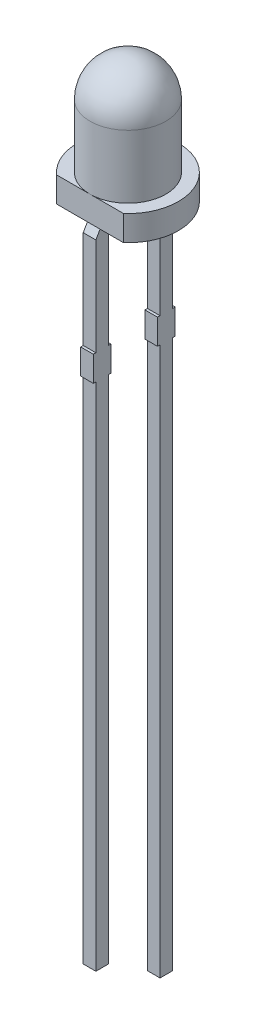
from build123d import *

# Parameters (mm, degrees)
EXTRUDE1_DEPTH     = 1
SKETCH3_W          = 0.7
SKETCH3_H          = 1
EXTRUDE2_DEPTH     = 0.25
SKETCH3_4_W        = 0.7
SKETCH3_4_H        = 1
EXTRUDE3_DEPTH     = 0.25
FILLET1_R          = 0.25
FILLET2_R          = 0.25
SKETCH4_W          = 0.026582279
SKETCH4_H          = 0.025316456
SKETCH4_H_2        = 0.025316455
CUT_EXTRUDE1_DEPTH = 0.01


with BuildPart() as part:
    # Sketch1 → Revolve1 (revolve)
    with BuildSketch(Plane.XY):
        with BuildLine():
            ThreePointArc((0, 4), (1.060660172, 3.560660172), (1.5, 2.5))
            Line((1.5, 2.5), (1.5, 0))
            Line((1.5, 0), (0, 0))
            Line((0, 0), (0, 4))
        make_face()
    revolve(axis=Axis((0, 0, 0), (0, 1, 0)))

    # Sketch2 → Extrude1 (add)
    with BuildSketch(Plane.XZ.offset(1)):
        with BuildLine():
            Line((-1.322875656, 1.5), (1.322875656, 1.5))
            ThreePointArc((1.322875656, 1.5), (0, -2), (-1.322875656, 1.5))
        make_face()
    extrude(amount=-EXTRUDE1_DEPTH)

    # Sketch4 → Cut-Extrude1 (cut)
    with BuildSketch(Plane.XZ.offset(1)):
        Polygon((-0.985888894, 0.474333212), (-1.060572439, 0.49779049), (-1.060572439, 0.52253337), (-1.010236204, 0.538949509), (-1.060572439, 0.554475617), (-1.060572439, 0.580207421), (-0.985888894, 0.603447136), (-0.985888894, 0.57826913), (-1.03737228, 0.565274668), (-0.985888894, 0.548858528), (-0.985888894, 0.52735932), (-1.03737228, 0.511042073), (-0.985888894, 0.498225617), align=None)
        Polygon((-0.985888894, 0.340155997), (-1.060572439, 0.363613275), (-1.060572439, 0.388356155), (-1.010236204, 0.404772294), (-1.060572439, 0.420298402), (-1.060572439, 0.446030206), (-0.985888894, 0.469269921), (-0.985888894, 0.444091914), (-1.03737228, 0.431097452), (-0.985888894, 0.414681313), (-0.985888894, 0.393182104), (-1.03737228, 0.376864858), (-0.985888894, 0.364048402), align=None)
        Polygon((-0.985888894, 0.205978782), (-1.060572439, 0.22943606), (-1.060572439, 0.25417894), (-1.010236204, 0.270595079), (-1.060572439, 0.286121187), (-1.060572439, 0.31185299), (-0.985888894, 0.335092706), (-0.985888894, 0.309914699), (-1.03737228, 0.296920237), (-0.985888894, 0.280504098), (-0.985888894, 0.259004889), (-1.03737228, 0.242687642), (-0.985888894, 0.229871187), align=None)
        with Locations((-1.0472813, 0.17813068)):
            Rectangle(SKETCH4_W, SKETCH4_H)
        with BuildLine():
            add(Edge.make_bspline(
                [(-1.029401552, 0.061674984), (-1.030623686, 0.061711482), (-1.033023549, 0.061783153), (-1.036531237, 0.062392739), (-1.03985554, 0.063386706), (-1.043019686, 0.064759045), (-1.045989175, 0.066552502), (-1.048792066, 0.068735773), (-1.05139661, 0.071324656), (-1.053832985, 0.07427146), (-1.056015096, 0.077568402), (-1.05792113, 0.081166117), (-1.059515801, 0.085046144), (-1.060854866, 0.089194355), (-1.0618433, 0.093640901), (-1.062567287, 0.0983584), (-1.063040605, 0.103351827), (-1.063082573, 0.106775404), (-1.063104084, 0.108530206)],
                knots=[0, 0, 0, 0, 0.907312236, 1.78165839, 2.635367075, 3.479697475, 4.336364812, 5.205276731, 6.11257575, 7.058770404, 8.040786331, 9.044147278, 10.078219212, 11.153049307, 12.278104542, 13.457648573, 14.696882856, 16, 16, 16, 16], degree=3))
            add(Edge.make_bspline(
                [(-1.063104084, 0.108530206), (-1.063080012, 0.110548461), (-1.063033388, 0.114457643), (-1.062604789, 0.120121168), (-1.061958649, 0.125389206), (-1.060992107, 0.13028492), (-1.059791342, 0.13488952), (-1.058500051, 0.139322787), (-1.057035635, 0.143604099), (-1.055935477, 0.146377189), (-1.055390477, 0.147750933)],
                knots=[0, 0, 0, 0, 1.203215828, 2.33052265, 3.384689099, 4.366106119, 5.303329643, 6.221311756, 7.118865988, 8, 8, 8, 8], degree=3))
            Line((-1.055390477, 0.147750933), (-1.031458515, 0.147750933))
            Line((-1.031458515, 0.147750933), (-1.031458515, 0.144902832))
            add(Edge.make_bspline(
                [(-1.031458515, 0.144902832), (-1.03253997, 0.143537518), (-1.03469653, 0.140814905), (-1.037459136, 0.136381672), (-1.039861299, 0.131734027), (-1.0418353, 0.126888556), (-1.043421624, 0.121991711), (-1.044515152, 0.117116334), (-1.045262501, 0.112350746), (-1.045343007, 0.109192177), (-1.045382565, 0.107640174)],
                knots=[0, 0, 0, 0, 1.030622468, 2.055194264, 3.087043286, 4.125157485, 5.149848264, 6.130935704, 7.081611712, 8, 8, 8, 8], degree=3))
            add(Edge.make_bspline(
                [(-1.045382565, 0.107640174), (-1.045381671, 0.107211395), (-1.045379756, 0.106293414), (-1.045250913, 0.104825377), (-1.045157749, 0.103166777), (-1.044948532, 0.101387911), (-1.044729948, 0.099597094), (-1.044349628, 0.097942434), (-1.04398779, 0.096438795), (-1.043619612, 0.095532313), (-1.043444274, 0.095100617)],
                knots=[0, 0, 0, 0, 0.806378557, 1.726393851, 2.771014456, 3.931269413, 5.096090628, 6.161710732, 7.124547685, 8, 8, 8, 8], degree=3))
            add(Edge.make_bspline(
                [(-1.043444274, 0.095100617), (-1.04321645, 0.09462083), (-1.042768728, 0.093677947), (-1.041951121, 0.092383028), (-1.04107982, 0.091200355), (-1.040114401, 0.090138895), (-1.038936492, 0.089288627), (-1.037535636, 0.088660426), (-1.035885336, 0.088317332), (-1.034710325, 0.088278039), (-1.034089052, 0.088257263)],
                knots=[0, 0, 0, 0, 1.024407818, 2.013179384, 2.949802342, 3.859052226, 4.77034807, 5.732977883, 6.801339628, 8, 8, 8, 8], degree=3))
            add(Edge.make_bspline(
                [(-1.034089052, 0.088257263), (-1.033543156, 0.088288704), (-1.032469764, 0.088350528), (-1.030941767, 0.088932319), (-1.029519891, 0.089815218), (-1.028259175, 0.09110224), (-1.027101737, 0.092696316), (-1.02613144, 0.094652053), (-1.025251366, 0.096905033), (-1.024834098, 0.098549492), (-1.02461516, 0.099412326)],
                knots=[0, 0, 0, 0, 0.825212765, 1.622611382, 2.449701629, 3.348069183, 4.336544339, 5.428209675, 6.6506027, 8, 8, 8, 8], degree=3))
            add(Edge.make_bspline(
                [(-1.02461516, 0.099412326), (-1.024167419, 0.101381053), (-1.02325023, 0.105413961), (-1.022103122, 0.11156207), (-1.020837049, 0.117692298), (-1.019627508, 0.121651009), (-1.019037628, 0.12358163)],
                knots=[0, 0, 0, 0, 0.976104583, 1.999535498, 3.024395274, 4, 4, 4, 4], degree=3))
            add(Edge.make_bspline(
                [(-1.019037628, 0.12358163), (-1.018684636, 0.124620145), (-1.017997503, 0.126641714), (-1.016835878, 0.129533258), (-1.015565926, 0.132194371), (-1.014210794, 0.134634481), (-1.012736796, 0.136833803), (-1.011203407, 0.138828993), (-1.009549569, 0.140572519), (-1.00781765, 0.142120202), (-1.005965647, 0.143443517), (-1.004021511, 0.144598267), (-1.001961045, 0.145573902), (-0.999799757, 0.146382786), (-0.997520888, 0.146999859), (-0.995144015, 0.147421115), (-0.992660654, 0.147719504), (-0.990966301, 0.147740314), (-0.990101711, 0.147750933)],
                knots=[0, 0, 0, 0, 1.287286806, 2.505824366, 3.654938963, 4.74627059, 5.778586806, 6.75996495, 7.696030012, 8.595059759, 9.482019644, 10.363222407, 11.245851011, 12.154256429, 13.068444161, 14.012503255, 14.985824751, 16, 16, 16, 16], degree=3))
            add(Edge.make_bspline(
                [(-0.990101711, 0.147750933), (-0.988945566, 0.147713632), (-0.986670294, 0.147640222), (-0.983341249, 0.147038793), (-0.980192513, 0.146012204), (-0.97718905, 0.14462614), (-0.974375964, 0.142797512), (-0.971697416, 0.140612718), (-0.969225825, 0.13798867), (-0.966925491, 0.135011549), (-0.964846093, 0.131724164), (-0.963015536, 0.128185181), (-0.961478885, 0.124415892), (-0.960204991, 0.120430345), (-0.95925032, 0.116211876), (-0.958531388, 0.111774643), (-0.958118207, 0.107100854), (-0.958066956, 0.103909433), (-0.958040793, 0.102280206)],
                knots=[0, 0, 0, 0, 0.894990994, 1.761326291, 2.609044902, 3.454222546, 4.315366365, 5.200560057, 6.125081389, 7.100429509, 8.110379559, 9.133447974, 10.182136699, 11.259192205, 12.370181258, 13.528580438, 14.738335141, 16, 16, 16, 16], degree=3))
            add(Edge.make_bspline(
                [(-0.958040793, 0.102280206), (-0.958062985, 0.100611519), (-0.95810733, 0.097276974), (-0.958485307, 0.092295531), (-0.959040536, 0.087335029), (-0.959882241, 0.082471199), (-0.960858658, 0.077780644), (-0.961954454, 0.073367408), (-0.963192418, 0.069287948), (-0.964146763, 0.066714283), (-0.964607249, 0.065472452)],
                knots=[0, 0, 0, 0, 1.065403572, 2.129000689, 3.188532477, 4.251604565, 5.279552602, 6.247508681, 7.154397237, 8, 8, 8, 8], degree=3))
            Line((-0.964607249, 0.065472452), (-0.987154717, 0.065472452))
            Line((-0.987154717, 0.065472452), (-0.987154717, 0.068300775))
            add(Edge.make_bspline(
                [(-0.987154717, 0.068300775), (-0.98635437, 0.06937368), (-0.984717641, 0.071567798), (-0.982633968, 0.075227435), (-0.980676103, 0.079185671), (-0.978991944, 0.083464501), (-0.977532462, 0.087923529), (-0.976513296, 0.092506488), (-0.975871487, 0.097132651), (-0.975798712, 0.100234362), (-0.975762312, 0.101785744)],
                knots=[0, 0, 0, 0, 0.892283326, 1.824742884, 2.804416662, 3.836872171, 4.8899239, 5.931447339, 6.965372909, 8, 8, 8, 8], degree=3))
            add(Edge.make_bspline(
                [(-0.975762312, 0.101785744), (-0.975783764, 0.102881411), (-0.975826667, 0.105072628), (-0.976217351, 0.108340836), (-0.976848244, 0.111582897), (-0.977667526, 0.11362342), (-0.978076394, 0.114641756)],
                knots=[0, 0, 0, 0, 0.999146175, 1.998183711, 3.000980573, 4, 4, 4, 4], degree=3))
            add(Edge.make_bspline(
                [(-0.978076394, 0.114641756), (-0.978277861, 0.11507526), (-0.97868066, 0.115941977), (-0.979453224, 0.117148622), (-0.980382035, 0.11825329), (-0.981434027, 0.119245368), (-0.982590401, 0.120113765), (-0.983865227, 0.120729117), (-0.985228142, 0.12110499), (-0.986163373, 0.121147148), (-0.986640477, 0.121168655)],
                knots=[0, 0, 0, 0, 1.00524851, 2.009826503, 3.004679593, 4.035271301, 5.048246368, 6.034938417, 6.997532266, 8, 8, 8, 8], degree=3))
            add(Edge.make_bspline(
                [(-0.986640477, 0.121168655), (-0.987278642, 0.121134217), (-0.988498118, 0.121068409), (-0.990213913, 0.120461824), (-0.991692347, 0.119476991), (-0.992687267, 0.118316386), (-0.993384706, 0.117199256), (-0.993895216, 0.116163597), (-0.994378575, 0.11495437), (-0.994876043, 0.113583122), (-0.995367231, 0.112046795), (-0.995842777, 0.110338238), (-0.996292073, 0.108455521), (-0.996578264, 0.107139646), (-0.996727502, 0.106453465)],
                knots=[0, 0, 0, 0, 1.173816843, 2.243057204, 3.312297565, 4.415174738, 5.03266065, 5.73970059, 6.541434878, 7.433956553, 8.430083051, 9.515931566, 10.70464786, 12, 12, 12, 12], degree=3))
            add(Edge.make_bspline(
                [(-0.996727502, 0.106453465), (-0.997103563, 0.104620676), (-0.997842441, 0.10101965), (-0.998945929, 0.095618466), (-1.000220899, 0.090115693), (-1.001369702, 0.086450366), (-1.001968799, 0.084538908)],
                knots=[0, 0, 0, 0, 0.995744513, 1.956417928, 2.934277412, 4, 4, 4, 4], degree=3))
            add(Edge.make_bspline(
                [(-1.001968799, 0.084538908), (-1.002288043, 0.083592354), (-1.002912536, 0.081740741), (-1.003998819, 0.07910011), (-1.005172801, 0.076653052), (-1.006414333, 0.074386019), (-1.007758299, 0.072312049), (-1.009180946, 0.070417367), (-1.010707855, 0.068733548), (-1.012321082, 0.067235983), (-1.014031183, 0.065916823), (-1.015870255, 0.064784525), (-1.017819057, 0.063812297), (-1.019905257, 0.063042692), (-1.022099845, 0.062424671), (-1.024431212, 0.062001574), (-1.026875589, 0.061707591), (-1.028550166, 0.061685974), (-1.029401552, 0.061674984)],
                knots=[0, 0, 0, 0, 1.237467875, 2.420686895, 3.535046182, 4.599015201, 5.620884487, 6.594603852, 7.531477383, 8.433220087, 9.318759595, 10.202828513, 11.105163009, 12.01247538, 12.953896178, 13.926381251, 14.945733412, 16, 16, 16, 16], degree=3))
        make_face()
        with BuildLine():
            Line((-1.060572439, -0.030730079), (-1.060572439, -0.006679446))
            Line((-1.060572439, -0.006679446), (-1.05274016, -0.006679446))
            add(Edge.make_bspline(
                [(-1.05274016, -0.006679446), (-1.053548718, -0.005586137), (-1.055107607, -0.003478254), (-1.057187824, -0.000305229), (-1.058963091, 0.002720862), (-1.060522311, 0.005634352), (-1.061697697, 0.008656555), (-1.062525763, 0.01188807), (-1.063025536, 0.015390894), (-1.063077319, 0.017817788), (-1.063104084, 0.019072136)],
                knots=[0, 0, 0, 0, 1.150872466, 2.218865267, 3.209461834, 4.120482262, 5.012764827, 5.946708227, 6.938749913, 8, 8, 8, 8], degree=3))
            add(Edge.make_bspline(
                [(-1.063104084, 0.019072136), (-1.063081365, 0.020088488), (-1.063037125, 0.022067618), (-1.062692247, 0.024944858), (-1.062154595, 0.027652486), (-1.061347004, 0.030167526), (-1.060381201, 0.032531515), (-1.059101243, 0.034669065), (-1.057671069, 0.036672667), (-1.055964024, 0.03845434), (-1.05406629, 0.040069961), (-1.05193383, 0.041452511), (-1.049600905, 0.042630222), (-1.047049051, 0.04357132), (-1.044290747, 0.044326409), (-1.0413115, 0.044850341), (-1.038124372, 0.045170934), (-1.035929242, 0.045202873), (-1.034801078, 0.045219288)],
                knots=[0, 0, 0, 0, 1.109008058, 2.159558935, 3.158726032, 4.116861086, 5.039058877, 5.938775559, 6.82970133, 7.720510853, 8.624361809, 9.544451588, 10.487360536, 11.471068125, 12.508000841, 13.604731202, 14.768976642, 16, 16, 16, 16], degree=3))
            Line((-1.034801078, 0.045219288), (-0.985888894, 0.045219288))
            Line((-0.985888894, 0.045219288), (-0.985888894, 0.021168655))
            Line((-0.985888894, 0.021168655), (-1.023468008, 0.021168655))
            add(Edge.make_bspline(
                [(-1.023468008, 0.021168655), (-1.024384479, 0.021167019), (-1.026138695, 0.021163889), (-1.028644501, 0.02108155), (-1.030912674, 0.020960649), (-1.032954703, 0.020821945), (-1.034801453, 0.020568928), (-1.036467614, 0.02019122), (-1.037987216, 0.019720393), (-1.038893918, 0.019256075), (-1.03933035, 0.019032579)],
                knots=[0, 0, 0, 0, 1.361401701, 2.605856924, 3.723918663, 4.735739235, 5.645738665, 6.489217889, 7.27279937, 8, 8, 8, 8], degree=3))
            add(Edge.make_bspline(
                [(-1.03933035, 0.019032579), (-1.039729065, 0.018802572), (-1.040512904, 0.018350399), (-1.041519082, 0.017430109), (-1.04236335, 0.016351366), (-1.043019379, 0.015073763), (-1.043518327, 0.013587214), (-1.043858564, 0.011859284), (-1.044074065, 0.009873922), (-1.044101974, 0.008464904), (-1.044116742, 0.007719288)],
                knots=[0, 0, 0, 0, 0.849138082, 1.669332372, 2.503455908, 3.370611167, 4.311442699, 5.394692208, 6.621337967, 8, 8, 8, 8], degree=3))
            add(Edge.make_bspline(
                [(-1.044116742, 0.007719288), (-1.044099385, 0.007178004), (-1.044063698, 0.006065087), (-1.043831252, 0.004353774), (-1.043474577, 0.002557197), (-1.042814722, 4.2614e-05), (-1.041628542, -0.003124013), (-1.040274135, -0.005483314), (-1.03958747, -0.006679446)],
                knots=[0, 0, 0, 0, 0.638127216, 1.312033637, 2.033062677, 2.79661882, 4.375931797, 6, 6, 6, 6], degree=3))
            Line((-1.03958747, -0.006679446), (-0.985888894, -0.006679446))
            Line((-0.985888894, -0.006679446), (-0.985888894, -0.030730079))
            Line((-0.985888894, -0.030730079), (-1.060572439, -0.030730079))
        make_face()
        with BuildLine():
            Line((-1.060572439, -0.128198434), (-1.060572439, -0.104147801))
            Line((-1.060572439, -0.104147801), (-1.022993325, -0.104147801))
            add(Edge.make_bspline(
                [(-1.022993325, -0.104147801), (-1.021463282, -0.104123286), (-1.018412257, -0.104074403), (-1.014649846, -0.103792279), (-1.011807522, -0.103413757), (-1.009969641, -0.103044101), (-1.008421501, -0.102612401), (-1.007535742, -0.102200121), (-1.007130983, -0.102011725)],
                knots=[0, 0, 0, 0, 1.709124929, 3.408128882, 4.211124727, 4.91016634, 5.501986363, 6, 6, 6, 6], degree=3))
            add(Edge.make_bspline(
                [(-1.007130983, -0.102011725), (-1.00673293, -0.101767262), (-1.00595249, -0.101287958), (-1.004939476, -0.100350634), (-1.004110636, -0.099256748), (-1.003429085, -0.097985979), (-1.002958504, -0.096494782), (-1.002565274, -0.094778041), (-1.002398366, -0.092791423), (-1.002363205, -0.091384153), (-1.00234459, -0.090639098)],
                knots=[0, 0, 0, 0, 0.86006424, 1.686277094, 2.52783008, 3.38194165, 4.331801563, 5.402842185, 6.624978739, 8, 8, 8, 8], degree=3))
            add(Edge.make_bspline(
                [(-1.00234459, -0.090639098), (-1.002401328, -0.089507276), (-1.002517181, -0.087196182), (-1.003228689, -0.084333989), (-1.004047648, -0.082003385), (-1.004806479, -0.08015086), (-1.00577792, -0.078242229), (-1.006499743, -0.076962817), (-1.006873863, -0.076299699)],
                knots=[0, 0, 0, 0, 1.338371478, 2.732853438, 3.468019217, 4.261884641, 5.099136535, 6, 6, 6, 6], degree=3))
            Line((-1.006873863, -0.076299699), (-1.060572439, -0.076299699))
            Line((-1.060572439, -0.076299699), (-1.060572439, -0.052249067))
            Line((-1.060572439, -0.052249067), (-0.985888894, -0.052249067))
            Line((-0.985888894, -0.052249067), (-0.985888894, -0.076299699))
            Line((-0.985888894, -0.076299699), (-0.993721173, -0.076299699))
            add(Edge.make_bspline(
                [(-0.993721173, -0.076299699), (-0.992915021, -0.077357106), (-0.991345799, -0.079415411), (-0.989305379, -0.082594648), (-0.987506609, -0.085678546), (-0.985993793, -0.088731556), (-0.984787018, -0.091846511), (-0.983976029, -0.095109269), (-0.983432226, -0.098525676), (-0.983382532, -0.100862391), (-0.983357249, -0.102051282)],
                knots=[0, 0, 0, 0, 1.126119141, 2.192057864, 3.198061997, 4.149848529, 5.076251285, 6.021887753, 6.99356175, 8, 8, 8, 8], degree=3))
            add(Edge.make_bspline(
                [(-0.983357249, -0.102051282), (-0.983382638, -0.103047553), (-0.983432202, -0.104992452), (-0.983741911, -0.107827213), (-0.984292575, -0.110498634), (-0.985090405, -0.112990908), (-0.986076017, -0.115333527), (-0.987307532, -0.117495472), (-0.988765955, -0.119487543), (-0.990426958, -0.121315943), (-0.992316684, -0.122946762), (-0.994433948, -0.124363798), (-0.996777045, -0.125543779), (-0.999337354, -0.126514491), (-1.002102463, -0.127288915), (-1.005098428, -0.127804046), (-1.008302607, -0.12815783), (-1.01051865, -0.128184628), (-1.011660255, -0.128198434)],
                knots=[0, 0, 0, 0, 1.08848837, 2.124922927, 3.110950502, 4.063144162, 4.979605775, 5.882838355, 6.774625441, 7.671951181, 8.57587277, 9.494821853, 10.448322275, 11.435533005, 12.482327682, 13.580118324, 14.753386918, 16, 16, 16, 16], degree=3))
            Line((-1.011660255, -0.128198434), (-1.060572439, -0.128198434))
        make_face()
        Polygon((-1.060572439, -0.223135142), (-1.060572439, -0.150983244), (-0.960572439, -0.150983244), (-0.960572439, -0.176299699), (-1.041585097, -0.176299699), (-1.041585097, -0.223135142), align=None)
        Polygon((-1.060572439, -0.310476915), (-1.060572439, -0.238325016), (-0.960572439, -0.238325016), (-0.960572439, -0.310476915), (-0.97955978, -0.310476915), (-0.97955978, -0.263641472), (-0.997281299, -0.263641472), (-0.997281299, -0.306679446), (-1.016268641, -0.306679446), (-1.016268641, -0.263641472), (-1.041585097, -0.263641472), (-1.041585097, -0.310476915), align=None)
        with BuildLine():
            add(Edge.make_bspline(
                [(-1.010671331, -0.426932611), (-1.01181902, -0.426913296), (-1.014091906, -0.426875043), (-1.017456713, -0.426579852), (-1.020722388, -0.426053827), (-1.023906637, -0.425374645), (-1.026985564, -0.424452139), (-1.029993141, -0.423370426), (-1.032898635, -0.42206078), (-1.035700069, -0.420555927), (-1.038372172, -0.418906455), (-1.040892381, -0.417131706), (-1.043275599, -0.415285927), (-1.045470493, -0.413296614), (-1.047512512, -0.411217433), (-1.049403326, -0.409041904), (-1.051106757, -0.40673684), (-1.052129642, -0.405129677), (-1.052641268, -0.404325807)],
                knots=[0, 0, 0, 0, 1.105570398, 2.18947457, 3.250358341, 4.290584537, 5.323553275, 6.344225964, 7.367641686, 8.3905646, 9.405808457, 10.390761353, 11.358902336, 12.307789878, 13.241960776, 14.165076779, 15.082208636, 16, 16, 16, 16], degree=3))
            add(Edge.make_bspline(
                [(-1.052641268, -0.404325807), (-1.053353407, -0.403086579), (-1.054781319, -0.400601799), (-1.05644991, -0.396617964), (-1.057854026, -0.392492482), (-1.058908451, -0.388142096), (-1.059635495, -0.383495086), (-1.060196301, -0.378493677), (-1.060498061, -0.373086087), (-1.060547081, -0.369351193), (-1.060572439, -0.367419161)],
                knots=[0, 0, 0, 0, 0.896288622, 1.797150563, 2.705281913, 3.629615989, 4.602417572, 5.655716007, 6.787320449, 8, 8, 8, 8], degree=3))
            Line((-1.060572439, -0.367419161), (-1.060572439, -0.331995902))
            Line((-1.060572439, -0.331995902), (-0.960572439, -0.331995902))
            Line((-0.960572439, -0.331995902), (-0.960572439, -0.368427864))
            add(Edge.make_bspline(
                [(-0.960572439, -0.368427864), (-0.96058905, -0.370406596), (-0.96062109, -0.374223324), (-0.961038681, -0.379740163), (-0.961635505, -0.384845371), (-0.962560376, -0.389530719), (-0.963675721, -0.393830724), (-0.965034849, -0.3977562), (-0.966533557, -0.401367974), (-0.96780725, -0.403546815), (-0.968424496, -0.404602706)],
                knots=[0, 0, 0, 0, 1.267175336, 2.444223962, 3.542125549, 4.557526608, 5.500936977, 6.385043188, 7.217374394, 8, 8, 8, 8], degree=3))
            add(Edge.make_bspline(
                [(-0.968424496, -0.404602706), (-0.968961036, -0.405453659), (-0.97002795, -0.407145784), (-0.971809802, -0.409546998), (-0.973765879, -0.411776426), (-0.975817698, -0.413904928), (-0.978020584, -0.415884746), (-0.980359292, -0.417727946), (-0.982837386, -0.419431763), (-0.985446855, -0.420989726), (-0.988176907, -0.422410541), (-0.991049966, -0.423599847), (-0.994028496, -0.424649196), (-0.997137458, -0.425454732), (-1.000345294, -0.426152646), (-1.003686638, -0.426587381), (-1.007139127, -0.426873992), (-1.009484016, -0.426912907), (-1.010671331, -0.426932611)],
                knots=[0, 0, 0, 0, 0.964065863, 1.917049184, 2.86229036, 3.805247319, 4.749389377, 5.698846072, 6.657678277, 7.629829384, 8.610569287, 9.604676042, 10.607940105, 11.6349849, 12.681042988, 13.752616828, 14.862056989, 16, 16, 16, 16], degree=3))
        make_face()
        with BuildLine():
            add(Edge.make_bspline(
                [(-1.010513103, -0.400350332), (-1.009708343, -0.400340092), (-1.008129759, -0.400320004), (-1.005814244, -0.400128437), (-1.003584595, -0.39986938), (-1.001449902, -0.399438326), (-0.999390332, -0.39893868), (-0.997432838, -0.39829653), (-0.995553265, -0.397572133), (-0.993775776, -0.396690496), (-0.992067393, -0.395716859), (-0.990481878, -0.394569366), (-0.988968992, -0.393321028), (-0.987541007, -0.391942741), (-0.986235111, -0.390399801), (-0.985005035, -0.388739698), (-0.983876709, -0.38693934), (-0.98321666, -0.385666352), (-0.982882565, -0.38502201)],
                knots=[0, 0, 0, 0, 1.152093354, 2.259898929, 3.325467225, 4.364140538, 5.376172865, 6.358396836, 7.312077728, 8.257828931, 9.196960457, 10.124297759, 11.056236784, 12.004246951, 12.961658638, 13.947279359, 14.960983522, 16, 16, 16, 16], degree=3))
            add(Edge.make_bspline(
                [(-0.982882565, -0.38502201), (-0.982575853, -0.384347112), (-0.981967929, -0.383009418), (-0.981236736, -0.380938595), (-0.980663901, -0.378849211), (-0.980233042, -0.376647612), (-0.979911111, -0.374177852), (-0.979713853, -0.37125227), (-0.979571684, -0.367796361), (-0.979563932, -0.365309646), (-0.97955978, -0.363977706)],
                knots=[0, 0, 0, 0, 0.826967603, 1.639107464, 2.447640171, 3.242670507, 4.14065217, 5.225198036, 6.513753944, 8, 8, 8, 8], degree=3))
            Line((-0.97955978, -0.363977706), (-0.97955978, -0.357312358))
            Line((-0.97955978, -0.357312358), (-1.041585097, -0.357312358))
            Line((-1.041585097, -0.357312358), (-1.041585097, -0.363977706))
            add(Edge.make_bspline(
                [(-1.041585097, -0.363977706), (-1.041580347, -0.364735913), (-1.041571178, -0.366199678), (-1.041528115, -0.368315922), (-1.041481228, -0.370281718), (-1.041364766, -0.372086589), (-1.04129212, -0.373745273), (-1.041113741, -0.375232055), (-1.040971561, -0.376574544), (-1.040703838, -0.378142141), (-1.040287655, -0.379995306), (-1.039609476, -0.382156567), (-1.03875908, -0.384297101), (-1.038074113, -0.385685674), (-1.037728293, -0.386386725)],
                knots=[0, 0, 0, 0, 1.186793418, 2.291178421, 3.313283093, 4.264083014, 5.122158624, 5.910777728, 6.607099052, 7.234812932, 8.398911528, 9.577194775, 10.776795607, 12, 12, 12, 12], degree=3))
            add(Edge.make_bspline(
                [(-1.037728293, -0.386386725), (-1.037386777, -0.386971841), (-1.036713262, -0.388125766), (-1.035579189, -0.389749271), (-1.034371464, -0.391256989), (-1.033083013, -0.392653001), (-1.031694771, -0.3939163), (-1.03022823, -0.39506832), (-1.028680251, -0.396098768), (-1.026486734, -0.397334157), (-1.023455797, -0.398557403), (-1.019488411, -0.399596946), (-1.015128647, -0.400233817), (-1.01209103, -0.400310499), (-1.010513103, -0.400350332)],
                knots=[0, 0, 0, 0, 0.755160452, 1.489275589, 2.205657296, 2.907868421, 3.605098304, 4.296256403, 4.985378686, 5.676536785, 7.100390329, 8.614249252, 10.241231541, 12, 12, 12, 12], degree=3))
        make_face(mode=Mode.SUBTRACT)
        with Locations((-1.0472813, -0.458578181)):
            Rectangle(SKETCH4_W, SKETCH4_H_2)
        with BuildLine():
            add(Edge.make_bspline(
                [(-1.063104084, -0.533222168), (-1.063082273, -0.531632055), (-1.063039461, -0.528510918), (-1.062562544, -0.523939577), (-1.061844849, -0.519574404), (-1.060823942, -0.515428096), (-1.059476446, -0.511514305), (-1.057823511, -0.507850667), (-1.055838326, -0.50444381), (-1.054259117, -0.502385163), (-1.053471964, -0.501359035)],
                knots=[0, 0, 0, 0, 1.123670284, 2.205584497, 3.245308791, 4.249063313, 5.220352711, 6.167273909, 7.086481357, 8, 8, 8, 8], degree=3))
            add(Edge.make_bspline(
                [(-1.053471964, -0.501359035), (-1.05261719, -0.500407287), (-1.050910947, -0.498507473), (-1.04793952, -0.496041539), (-1.044656476, -0.493918454), (-1.041054253, -0.492132901), (-1.037137525, -0.490701978), (-1.032892862, -0.489678844), (-1.028332082, -0.489059598), (-1.025184148, -0.488992433), (-1.023566901, -0.488957927)],
                knots=[0, 0, 0, 0, 0.916457077, 1.82937027, 2.759194969, 3.714948755, 4.706655623, 5.743329475, 6.840637961, 8, 8, 8, 8], degree=3))
            add(Edge.make_bspline(
                [(-1.023566901, -0.488957927), (-1.021863673, -0.488996688), (-1.018562593, -0.489071811), (-1.013790406, -0.48973557), (-1.009372725, -0.490805182), (-1.005320817, -0.492342741), (-1.001627625, -0.494273182), (-0.998255791, -0.496537675), (-0.995212867, -0.499158201), (-0.993467427, -0.501165339), (-0.992593799, -0.502169953)],
                knots=[0, 0, 0, 0, 1.171797512, 2.271099083, 3.308930235, 4.294129479, 5.24602549, 6.17106565, 7.084581485, 8, 8, 8, 8], degree=3))
            add(Edge.make_bspline(
                [(-0.992593799, -0.502169953), (-0.991825213, -0.503195823), (-0.990278757, -0.505259954), (-0.988378057, -0.508663459), (-0.986783272, -0.512286675), (-0.985535627, -0.516116245), (-0.984581721, -0.520089054), (-0.983857878, -0.524148714), (-0.983437319, -0.528294966), (-0.983384067, -0.531085167), (-0.983357249, -0.532490364)],
                knots=[0, 0, 0, 0, 0.952130878, 1.915761808, 2.890227217, 3.891541892, 4.905612075, 5.925811839, 6.955400088, 8, 8, 8, 8], degree=3))
            add(Edge.make_bspline(
                [(-0.983357249, -0.532490364), (-0.983374251, -0.533737083), (-0.983407683, -0.536188554), (-0.983729792, -0.539789601), (-0.984262911, -0.543244142), (-0.985001514, -0.546549074), (-0.985893117, -0.54972302), (-0.986932259, -0.552773197), (-0.988065526, -0.555733008), (-0.988950061, -0.557633576), (-0.989389685, -0.55857818)],
                knots=[0, 0, 0, 0, 1.107648782, 2.178012834, 3.209595929, 4.211695017, 5.185427128, 6.137685403, 7.07440854, 8, 8, 8, 8], degree=3))
            Line((-0.989389685, -0.55857818), (-1.009939527, -0.55857818))
            Line((-1.009939527, -0.55857818), (-1.009939527, -0.555235617))
            add(Edge.make_bspline(
                [(-1.009939527, -0.555235617), (-1.009522307, -0.554736073), (-1.008620593, -0.553656437), (-1.007199841, -0.551870021), (-1.005670247, -0.54972108), (-1.004778301, -0.548067543), (-1.00430266, -0.547185775)],
                knots=[0, 0, 0, 0, 0.792826818, 1.713491785, 2.780691913, 4, 4, 4, 4], degree=3))
            add(Edge.make_bspline(
                [(-1.00430266, -0.547185775), (-1.003860702, -0.54625784), (-1.002954842, -0.544355895), (-1.002122008, -0.541799891), (-1.001554282, -0.539607889), (-1.001297861, -0.537790353), (-1.001108299, -0.535856732), (-1.001088792, -0.53452149), (-1.001078768, -0.533835301)],
                knots=[0, 0, 0, 0, 1.332524827, 2.731214173, 3.480270227, 4.267952375, 5.109889624, 6, 6, 6, 6], degree=3))
            add(Edge.make_bspline(
                [(-1.001078768, -0.533835301), (-1.001098317, -0.533069745), (-1.001136204, -0.531586134), (-1.001413259, -0.529424626), (-1.001891517, -0.527406215), (-1.002531617, -0.525502993), (-1.003419231, -0.52376493), (-1.004452868, -0.522138089), (-1.005678669, -0.52064583), (-1.007119612, -0.519326569), (-1.00869954, -0.518133842), (-1.010433656, -0.517114641), (-1.012280255, -0.516202185), (-1.014284704, -0.515507247), (-1.01641348, -0.514947509), (-1.0186766, -0.514558579), (-1.02107611, -0.51431662), (-1.022722418, -0.514288703), (-1.023566901, -0.514274383)],
                knots=[0, 0, 0, 0, 1.087302107, 2.107140881, 3.088415001, 4.030197574, 4.951552271, 5.852940509, 6.764198256, 7.685219758, 8.621679636, 9.570836121, 10.538340132, 11.542450476, 12.578202196, 13.66207107, 14.800746211, 16, 16, 16, 16], degree=3))
            add(Edge.make_bspline(
                [(-1.023566901, -0.514274383), (-1.024431057, -0.514289157), (-1.026110069, -0.514317863), (-1.02855168, -0.514551378), (-1.030833112, -0.514967269), (-1.032958432, -0.515538517), (-1.03492445, -0.516262865), (-1.036721846, -0.517167982), (-1.038378654, -0.518204338), (-1.039841266, -0.519448896), (-1.041157587, -0.52081278), (-1.042293722, -0.522327672), (-1.043241867, -0.523986911), (-1.04404633, -0.525769091), (-1.044624728, -0.527702132), (-1.04506142, -0.529758669), (-1.045349976, -0.531948224), (-1.045371539, -0.533458578), (-1.045382565, -0.53423087)],
                knots=[0, 0, 0, 0, 1.230336593, 2.390482092, 3.487897344, 4.52859895, 5.520747884, 6.465347575, 7.38981449, 8.296085817, 9.192433006, 10.084246191, 10.984321635, 11.908883871, 12.862027947, 13.850751296, 14.901019963, 16, 16, 16, 16], degree=3))
            add(Edge.make_bspline(
                [(-1.045382565, -0.53423087), (-1.045374438, -0.534956725), (-1.045358593, -0.53637175), (-1.045140516, -0.538436496), (-1.044864634, -0.540397405), (-1.044425226, -0.542232945), (-1.043882851, -0.543928211), (-1.043316345, -0.545488634), (-1.04271156, -0.546901082), (-1.042244006, -0.547762436), (-1.042020223, -0.548174699)],
                knots=[0, 0, 0, 0, 1.200823684, 2.340960236, 3.433630075, 4.476504061, 5.46014544, 6.378484521, 7.223905657, 8, 8, 8, 8], degree=3))
            add(Edge.make_bspline(
                [(-1.042020223, -0.548174699), (-1.041590329, -0.548874905), (-1.040758687, -0.550229472), (-1.039357121, -0.5520682), (-1.037942861, -0.553713069), (-1.036986643, -0.55473758), (-1.036521806, -0.555235617)],
                knots=[0, 0, 0, 0, 1.098601379, 2.125273733, 3.088655601, 4, 4, 4, 4], degree=3))
            Line((-1.036521806, -0.555235617), (-1.036521806, -0.55857818))
            Line((-1.036521806, -0.55857818), (-1.057229875, -0.55857818))
            add(Edge.make_bspline(
                [(-1.057229875, -0.55857818), (-1.057667369, -0.557632791), (-1.058542463, -0.555741783), (-1.059696335, -0.552827204), (-1.060664495, -0.549839231), (-1.061567576, -0.546790859), (-1.062255938, -0.543618775), (-1.062749061, -0.540295745), (-1.063049973, -0.536814246), (-1.063085801, -0.534435857), (-1.063104084, -0.533222168)],
                knots=[0, 0, 0, 0, 0.952012952, 1.904254716, 2.862729541, 3.822037426, 4.808956931, 5.82647221, 6.890850784, 8, 8, 8, 8], degree=3))
        make_face()
        with BuildLine():
            add(Edge.make_bspline(
                [(-1.023270223, -0.650983244), (-1.024775129, -0.650958548), (-1.027708595, -0.65091041), (-1.031980386, -0.650371093), (-1.036016384, -0.649558314), (-1.039803593, -0.648385782), (-1.043360867, -0.64690539), (-1.04665066, -0.645054451), (-1.049703889, -0.642883446), (-1.052493774, -0.640392409), (-1.054992285, -0.637591207), (-1.057187538, -0.634517025), (-1.059000979, -0.631143198), (-1.06051307, -0.627528887), (-1.061682305, -0.623644235), (-1.062495022, -0.619490015), (-1.063030493, -0.615072881), (-1.063079144, -0.612034463), (-1.063104084, -0.610476915)],
                knots=[0, 0, 0, 0, 1.120167703, 2.183507516, 3.201345984, 4.182878364, 5.131270247, 6.065524964, 6.98789854, 7.91635504, 8.84481154, 9.778033504, 10.722808862, 11.691211189, 12.691525459, 13.738229926, 14.840575679, 16, 16, 16, 16], degree=3))
            add(Edge.make_bspline(
                [(-1.063104084, -0.610476915), (-1.063079062, -0.608919393), (-1.06303025, -0.605881028), (-1.062495918, -0.601463518), (-1.061677968, -0.597304424), (-1.060521867, -0.593415117), (-1.058995317, -0.589806371), (-1.057188269, -0.586436504), (-1.054992076, -0.583362739), (-1.052493884, -0.580561253), (-1.049703658, -0.578070934), (-1.046651475, -0.575897344), (-1.043355521, -0.574054929), (-1.039812475, -0.572537076), (-1.036011638, -0.571403751), (-1.031981196, -0.570580289), (-1.027708376, -0.570044081), (-1.024775055, -0.569995505), (-1.023270223, -0.569970586)],
                knots=[0, 0, 0, 0, 1.15937715, 2.261678054, 3.308339936, 4.313313916, 5.277148057, 6.221884977, 7.155068972, 8.083487698, 9.011906424, 9.934242473, 10.868459181, 11.818729666, 12.798784262, 13.81658132, 14.879877871, 16, 16, 16, 16], degree=3))
            add(Edge.make_bspline(
                [(-1.023270223, -0.569970586), (-1.0217588, -0.569995708), (-1.018805789, -0.570044794), (-1.014506917, -0.570580164), (-1.010446266, -0.571398181), (-1.006637953, -0.572558213), (-1.003086353, -0.574074486), (-0.999784248, -0.575915511), (-0.996737674, -0.578111978), (-0.993947922, -0.580621477), (-0.991451541, -0.583433271), (-0.989278635, -0.586527202), (-0.987441978, -0.589879122), (-0.985920145, -0.593486321), (-0.98478558, -0.597372876), (-0.983968001, -0.601509819), (-0.983429928, -0.605907213), (-0.983381916, -0.608925951), (-0.983357249, -0.610476915)],
                knots=[0, 0, 0, 0, 1.124034801, 2.196132384, 3.217834281, 4.203147447, 5.152578239, 6.085969439, 7.010345409, 7.941219594, 8.872481455, 9.802010446, 10.748267785, 11.711250247, 12.709230373, 13.754967386, 14.846549946, 16, 16, 16, 16], degree=3))
            add(Edge.make_bspline(
                [(-0.983357249, -0.610476915), (-0.983381971, -0.612047652), (-0.983430103, -0.615105817), (-0.983966306, -0.619549228), (-0.984779311, -0.623723068), (-0.985945707, -0.627621693), (-0.987457121, -0.631247443), (-0.989291779, -0.634607518), (-0.991493837, -0.637678826), (-0.994000993, -0.640466079), (-0.996806394, -0.642946321), (-0.999856018, -0.645115237), (-1.003175734, -0.646922454), (-1.006730602, -0.648404225), (-1.010524371, -0.649576398), (-1.014558477, -0.650397383), (-1.018833474, -0.650903374), (-1.021765604, -0.650956158), (-1.023270223, -0.650983244)],
                knots=[0, 0, 0, 0, 1.167358552, 2.272800965, 3.322628764, 4.326027541, 5.29287265, 6.238482395, 7.166210353, 8.096447471, 9.020151799, 9.945039072, 10.873038967, 11.824425184, 12.804379233, 13.820580988, 14.881633558, 16, 16, 16, 16], degree=3))
        make_face()
        with BuildLine():
            add(Edge.make_bspline(
                [(-1.041763103, -0.621275965), (-1.041263097, -0.621631143), (-1.040245524, -0.622353972), (-1.038545101, -0.623224224), (-1.036723307, -0.624012229), (-1.034694025, -0.624630424), (-1.03239158, -0.625109746), (-1.029737987, -0.625421137), (-1.026702475, -0.625650781), (-1.024549762, -0.625661243), (-1.023408673, -0.625666788)],
                knots=[0, 0, 0, 0, 0.764956307, 1.556776596, 2.379454426, 3.241401993, 4.200532455, 5.312591107, 6.575484591, 8, 8, 8, 8], degree=3))
            add(Edge.make_bspline(
                [(-1.023408673, -0.625666788), (-1.022333791, -0.625649099), (-1.020274435, -0.625615209), (-1.017314672, -0.625428839), (-1.014631246, -0.625080165), (-1.012213849, -0.624582286), (-1.010043161, -0.623972516), (-1.008100799, -0.623246581), (-1.006382197, -0.622408063), (-1.005376965, -0.621722596), (-1.004896015, -0.621394636)],
                knots=[0, 0, 0, 0, 1.337076348, 2.561692668, 3.686680134, 4.69989255, 5.629188848, 6.488203485, 7.276684665, 8, 8, 8, 8], degree=3))
            add(Edge.make_bspline(
                [(-1.004896015, -0.621394636), (-1.004456732, -0.621057338), (-1.003594975, -0.620395649), (-1.00251279, -0.619219598), (-1.001614496, -0.617955039), (-1.000954456, -0.616574737), (-1.000435198, -0.61512957), (-1.000088361, -0.613621244), (-0.99986024, -0.612066092), (-0.999828862, -0.611011756), (-0.999812945, -0.610476915)],
                knots=[0, 0, 0, 0, 1.058684453, 2.076859345, 3.046867319, 4.017860406, 4.996047344, 5.981941452, 6.976284511, 8, 8, 8, 8], degree=3))
            add(Edge.make_bspline(
                [(-0.999812945, -0.610476915), (-0.999823891, -0.609948983), (-0.999845302, -0.608916365), (-1.000024984, -0.6074137), (-1.000319574, -0.606002752), (-1.000737506, -0.604662878), (-1.001332989, -0.603370903), (-1.002189414, -0.602136559), (-1.003264745, -0.600920622), (-1.004115263, -0.600182375), (-1.00455978, -0.599796535)],
                knots=[0, 0, 0, 0, 1.041978199, 2.038073998, 2.982578265, 3.884042198, 4.804014415, 5.778706634, 6.839057036, 8, 8, 8, 8], degree=3))
            add(Edge.make_bspline(
                [(-1.00455978, -0.599796535), (-1.005034406, -0.59946305), (-1.006033007, -0.598761406), (-1.007737527, -0.597878431), (-1.009699447, -0.597147077), (-1.011883188, -0.596454837), (-1.014354337, -0.595936573), (-1.017107615, -0.595535834), (-1.020162042, -0.59533512), (-1.022294259, -0.595303544), (-1.023408673, -0.595287041)],
                knots=[0, 0, 0, 0, 0.706185926, 1.485796665, 2.33004681, 3.254820698, 4.274138656, 5.402098861, 6.642194297, 8, 8, 8, 8], degree=3))
            add(Edge.make_bspline(
                [(-1.023408673, -0.595287041), (-1.024411136, -0.595296188), (-1.026352249, -0.595313898), (-1.029158634, -0.595512813), (-1.031762566, -0.595841488), (-1.034152598, -0.596318133), (-1.036337496, -0.596892377), (-1.038289155, -0.597639851), (-1.040044213, -0.598463325), (-1.041071954, -0.599163663), (-1.041565318, -0.599499858)],
                knots=[0, 0, 0, 0, 1.270915159, 2.460926195, 3.565223763, 4.596447547, 5.549594966, 6.425286377, 7.244063354, 8, 8, 8, 8], degree=3))
            add(Edge.make_bspline(
                [(-1.041565318, -0.599499858), (-1.041981804, -0.599840418), (-1.042802932, -0.600511855), (-1.043886948, -0.601660773), (-1.044748298, -0.602944485), (-1.045478787, -0.604295688), (-1.046008033, -0.605757491), (-1.046384639, -0.607309383), (-1.046600393, -0.608961117), (-1.046632121, -0.610093912), (-1.046648388, -0.610674699)],
                knots=[0, 0, 0, 0, 1.011121112, 1.993489184, 2.956264801, 3.910060304, 4.874908638, 5.87009835, 6.907993364, 8, 8, 8, 8], degree=3))
            add(Edge.make_bspline(
                [(-1.046648388, -0.610674699), (-1.046594805, -0.611675649), (-1.046487883, -0.613673011), (-1.045776231, -0.616088161), (-1.044926952, -0.617895484), (-1.044047697, -0.619134754), (-1.043008158, -0.620290946), (-1.04218218, -0.620944414), (-1.041763103, -0.621275965)],
                knots=[0, 0, 0, 0, 1.48399549, 2.96126462, 3.700919455, 4.439278468, 5.208134679, 6, 6, 6, 6], degree=3))
        make_face(mode=Mode.SUBTRACT)
        with BuildLine():
            Line((-1.006873863, -0.742122484), (-1.060572439, -0.742122484))
            Line((-1.060572439, -0.742122484), (-1.060572439, -0.718071851))
            Line((-1.060572439, -0.718071851), (-1.022716426, -0.718071851))
            add(Edge.make_bspline(
                [(-1.022716426, -0.718071851), (-1.021826391, -0.718066385), (-1.02011876, -0.718055897), (-1.017659146, -0.718022873), (-1.015410542, -0.717942602), (-1.013364343, -0.717835063), (-1.011504878, -0.717648118), (-1.009830042, -0.717336778), (-1.008324517, -0.716915282), (-1.007423569, -0.716506931), (-1.006992534, -0.716311567)],
                knots=[0, 0, 0, 0, 1.339742217, 2.570446543, 3.702449567, 4.726327994, 5.654556215, 6.512888379, 7.288529137, 8, 8, 8, 8], degree=3))
            add(Edge.make_bspline(
                [(-1.006992534, -0.716311567), (-1.006607166, -0.716101641), (-1.005843273, -0.715685516), (-1.004875412, -0.714817471), (-1.004064767, -0.713809162), (-1.003423313, -0.712629001), (-1.00292515, -0.711250317), (-1.002575805, -0.709635196), (-1.002395403, -0.707771339), (-1.002362166, -0.706449051), (-1.00234459, -0.705749858)],
                knots=[0, 0, 0, 0, 0.859345536, 1.703436662, 2.532498256, 3.390183975, 4.328249457, 5.402602062, 6.626559876, 8, 8, 8, 8], degree=3))
            add(Edge.make_bspline(
                [(-1.00234459, -0.705749858), (-1.002368153, -0.705162563), (-1.00241549, -0.703982677), (-1.002657029, -0.702224203), (-1.003158975, -0.70050499), (-1.003995613, -0.698286314), (-1.00521208, -0.69567701), (-1.006333969, -0.693704594), (-1.006873863, -0.692755396)],
                knots=[0, 0, 0, 0, 0.759443456, 1.525737455, 2.286422378, 3.068189154, 4.58910569, 6, 6, 6, 6], degree=3))
            Line((-1.006873863, -0.692755396), (-1.060572439, -0.692755396))
            Line((-1.060572439, -0.692755396), (-1.060572439, -0.668704763))
            Line((-1.060572439, -0.668704763), (-0.985888894, -0.668704763))
            Line((-0.985888894, -0.668704763), (-0.985888894, -0.692755396))
            Line((-0.985888894, -0.692755396), (-0.993721173, -0.692755396))
            add(Edge.make_bspline(
                [(-0.993721173, -0.692755396), (-0.992939691, -0.693776433), (-0.99142237, -0.695758874), (-0.989376434, -0.698772847), (-0.987612999, -0.70172833), (-0.986082441, -0.704629446), (-0.98482706, -0.707575893), (-0.983990294, -0.710670393), (-0.983457975, -0.71391314), (-0.983391233, -0.716131423), (-0.983357249, -0.717260934)],
                knots=[0, 0, 0, 0, 1.136140478, 2.205924536, 3.217129804, 4.176128364, 5.103417168, 6.04061054, 7.002313223, 8, 8, 8, 8], degree=3))
            add(Edge.make_bspline(
                [(-0.983357249, -0.717260934), (-0.983388994, -0.718464177), (-0.983451038, -0.720815832), (-0.9841203, -0.724227753), (-0.985124925, -0.727443641), (-0.986615357, -0.730399648), (-0.988448158, -0.733121791), (-0.990725866, -0.735512772), (-0.993371672, -0.737627312), (-0.995383307, -0.73871744), (-0.996411046, -0.739274383)],
                knots=[0, 0, 0, 0, 1.06605855, 2.083537511, 3.073064962, 4.046068917, 5.009676085, 5.97370914, 6.964773701, 8, 8, 8, 8], degree=3))
            add(Edge.make_bspline(
                [(-0.996411046, -0.739274383), (-0.995434087, -0.740456469), (-0.993530182, -0.742760128), (-0.990987486, -0.746313722), (-0.988733186, -0.749792879), (-0.986823472, -0.75323313), (-0.985278584, -0.756628782), (-0.984172984, -0.760007909), (-0.983489537, -0.76335669), (-0.983400836, -0.765589949), (-0.983357249, -0.766687358)],
                knots=[0, 0, 0, 0, 1.188124574, 2.315425566, 3.384037189, 4.39937427, 5.362203716, 6.270239573, 7.150007311, 8, 8, 8, 8], degree=3))
            add(Edge.make_bspline(
                [(-0.983357249, -0.766687358), (-0.983380623, -0.767670616), (-0.983426104, -0.769583775), (-0.9837614, -0.772366217), (-0.984332138, -0.774962805), (-0.985126391, -0.777385371), (-0.986149807, -0.779628612), (-0.987423637, -0.781679467), (-0.988929817, -0.783534049), (-0.990629623, -0.785226938), (-0.99256397, -0.786708268), (-0.994691631, -0.78801188), (-0.997042649, -0.789060257), (-0.999570764, -0.789965474), (-1.002308041, -0.790647263), (-1.00525064, -0.791138005), (-1.008390661, -0.791436023), (-1.010551997, -0.791471422), (-1.011660255, -0.791489573)],
                knots=[0, 0, 0, 0, 1.099321551, 2.138985818, 3.128101353, 4.067593225, 4.984602876, 5.878565082, 6.75932895, 7.650734189, 8.554641537, 9.477588118, 10.434248276, 11.427530835, 12.477080043, 13.583595796, 14.760951851, 16, 16, 16, 16], degree=3))
            Line((-1.011660255, -0.791489573), (-1.060572439, -0.791489573))
            Line((-1.060572439, -0.791489573), (-1.060572439, -0.76743894))
            Line((-1.060572439, -0.76743894), (-1.022716426, -0.76743894))
            add(Edge.make_bspline(
                [(-1.022716426, -0.76743894), (-1.02181981, -0.767433229), (-1.020099014, -0.76742227), (-1.017632661, -0.767392589), (-1.015384844, -0.767302953), (-1.013344952, -0.767222407), (-1.011492819, -0.767053786), (-1.00982117, -0.766766753), (-1.008329181, -0.766336626), (-1.007424257, -0.765944734), (-1.006992534, -0.765757769)],
                knots=[0, 0, 0, 0, 1.350843832, 2.592553583, 3.715618503, 4.739861077, 5.667890227, 6.515410335, 7.291728161, 8, 8, 8, 8], degree=3))
            add(Edge.make_bspline(
                [(-1.006992534, -0.765757769), (-1.006607527, -0.765554392), (-1.005845269, -0.765151735), (-1.004870298, -0.764302618), (-1.004059689, -0.763290797), (-1.00342436, -0.762093806), (-1.002921896, -0.760690346), (-1.002580453, -0.759053995), (-1.00239299, -0.757165061), (-1.002361427, -0.755829413), (-1.00234459, -0.755116946)],
                knots=[0, 0, 0, 0, 0.846473755, 1.675897046, 2.498822796, 3.361436039, 4.304631926, 5.39613934, 6.611038701, 8, 8, 8, 8], degree=3))
            add(Edge.make_bspline(
                [(-1.00234459, -0.755116946), (-1.002391826, -0.754115972), (-1.002486844, -0.752102455), (-1.003203593, -0.749619078), (-1.004018226, -0.747597289), (-1.004797498, -0.745897343), (-1.005766825, -0.744056157), (-1.006493964, -0.742786056), (-1.006873863, -0.742122484)],
                knots=[0, 0, 0, 0, 1.291138276, 2.597198332, 3.312242316, 4.108946311, 5.012008063, 6, 6, 6, 6], degree=3))
        make_face()
    extrude(amount=-CUT_EXTRUDE1_DEPTH, mode=Mode.SUBTRACT)


with BuildPart() as body_2:
    # Sketch3 → Extrude2 (new body, symmetric)
    with BuildSketch(Plane(origin=(0, 0, 0), x_dir=(0, 0, -1), z_dir=(1, 0, 0))):
        Polygon((-1.52, -1.433012702), (-1.52, -26.5), (-1.02, -26.5), (-1.02, -1.3), (-0.42, -1.3), (-0.42, -1), (-1.27, -1), align=None)
        with Locations((-1.27, -5.8)):
            Rectangle(SKETCH3_W, SKETCH3_H)
    extrude(amount=EXTRUDE2_DEPTH, both=True)

    # Fillet1
    fillet1_edges = [body_2.edges().sort_by_distance(p)[0] for p in [
        (0, -1.3, 1.02),
    ]]
    fillet(fillet1_edges, radius=FILLET1_R)


with BuildPart() as body_3:
    # Sketch3_4 → Extrude3 (new body, symmetric)
    with BuildSketch(Plane(origin=(0, 0, 0), x_dir=(0, 0, -1), z_dir=(1, 0, 0))):
        Polygon((0.42, -1), (1.27, -1), (1.52, -1.433012702), (1.52, -28), (1.02, -28), (1.02, -1.3), (0.42, -1.3), align=None)
        with Locations((1.27, -5.8)):
            Rectangle(SKETCH3_4_W, SKETCH3_4_H)
    extrude(amount=EXTRUDE3_DEPTH, both=True)

    # Fillet2
    fillet2_edges = [body_3.edges().sort_by_distance(p)[0] for p in [
        (0, -1.3, -1.02),
    ]]
    fillet(fillet2_edges, radius=FILLET2_R)


solid = Compound([part.part, body_2.part, body_3.part])
